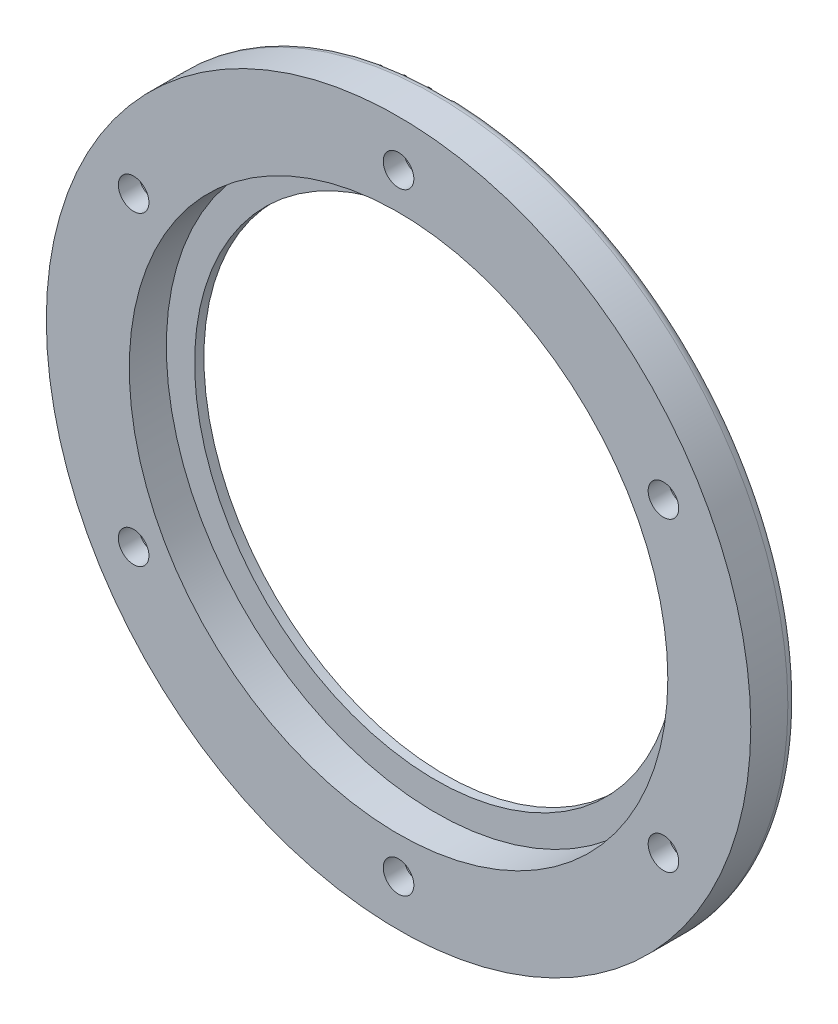
from build123d import *

# Parameters (mm, degrees)
SKETCH_1_W                    = 38
SKETCH_1_H                    = 5
HOLE_WIZARD_M48_1_D           = 52
HOLE_WIZARD_M48_1_DEPTH       = 5
HOLE_WIZARD_M48_1_CBORE_D     = 58.1
HOLE_WIZARD_M48_1_CBORE_DEPTH = 4
SKETCH_16_R                   = 1.65
CUT_EXTRUDE_9_DEPTH           = 6
SKETCH_17_R                   = 3
CUT_EXTRUDE_10_DEPTH          = 2.8
FILLET_2_R                    = 1


with BuildPart() as part:
    # 草图1 → 旋转1 (revolve)
    with BuildSketch(Plane(origin=(0, 0, 0), x_dir=(1, 0, 0), z_dir=(0, 1, 0))):
        with Locations((19, 26.5)):
            Rectangle(SKETCH_1_W, SKETCH_1_H)
    revolve(axis=Axis((0, 0, -29), (0, 0, 1)))

    # M48 六角头螺栓的柱形沉头孔1
    with Locations(Plane.XY.offset(-24)):
        with Locations((0, 0)):
            CounterBoreHole(HOLE_WIZARD_M48_1_D / 2, HOLE_WIZARD_M48_1_CBORE_D / 2, HOLE_WIZARD_M48_1_CBORE_DEPTH, depth=HOLE_WIZARD_M48_1_DEPTH)

    # 草图16 → 切除-拉伸9 (cut, through all)
    with BuildSketch(Plane(origin=(0, 0, -29), x_dir=(-1, 0, 0), z_dir=(0, 0, -1))):
        with Locations((0, -33)):
            Circle(SKETCH_16_R)
        with Locations((-28.578838325, -16.5)):
            Circle(SKETCH_16_R)
        with Locations((-28.578838325, 16.5)):
            Circle(SKETCH_16_R)
        with Locations((0, 33)):
            Circle(SKETCH_16_R)
        with Locations((28.578838325, 16.5)):
            Circle(SKETCH_16_R)
        with Locations((28.578838325, -16.5)):
            Circle(SKETCH_16_R)
    extrude(amount=-CUT_EXTRUDE_9_DEPTH, mode=Mode.SUBTRACT)

    # 草图17 → 切除-拉伸10 (cut)
    with BuildSketch(Plane(origin=(0, 0, -29), x_dir=(-1, 0, 0), z_dir=(0, 0, -1))):
        with Locations((0, -33)):
            Circle(SKETCH_17_R)
        with Locations((-28.578838325, -16.5)):
            Circle(SKETCH_17_R)
        with Locations((-28.578838325, 16.5)):
            Circle(SKETCH_17_R)
        with Locations((0, 33)):
            Circle(SKETCH_17_R)
        with Locations((28.578838325, 16.5)):
            Circle(SKETCH_17_R)
        with Locations((28.578838325, -16.5)):
            Circle(SKETCH_17_R)
    extrude(amount=-CUT_EXTRUDE_10_DEPTH, mode=Mode.SUBTRACT)

    # 圆角2
    fillet_2_edges = [part.edges().sort_by_distance(p)[0] for p in [
        (-38, 0, -29),
    ]]
    fillet(fillet_2_edges, radius=FILLET_2_R)


solid = part.part
